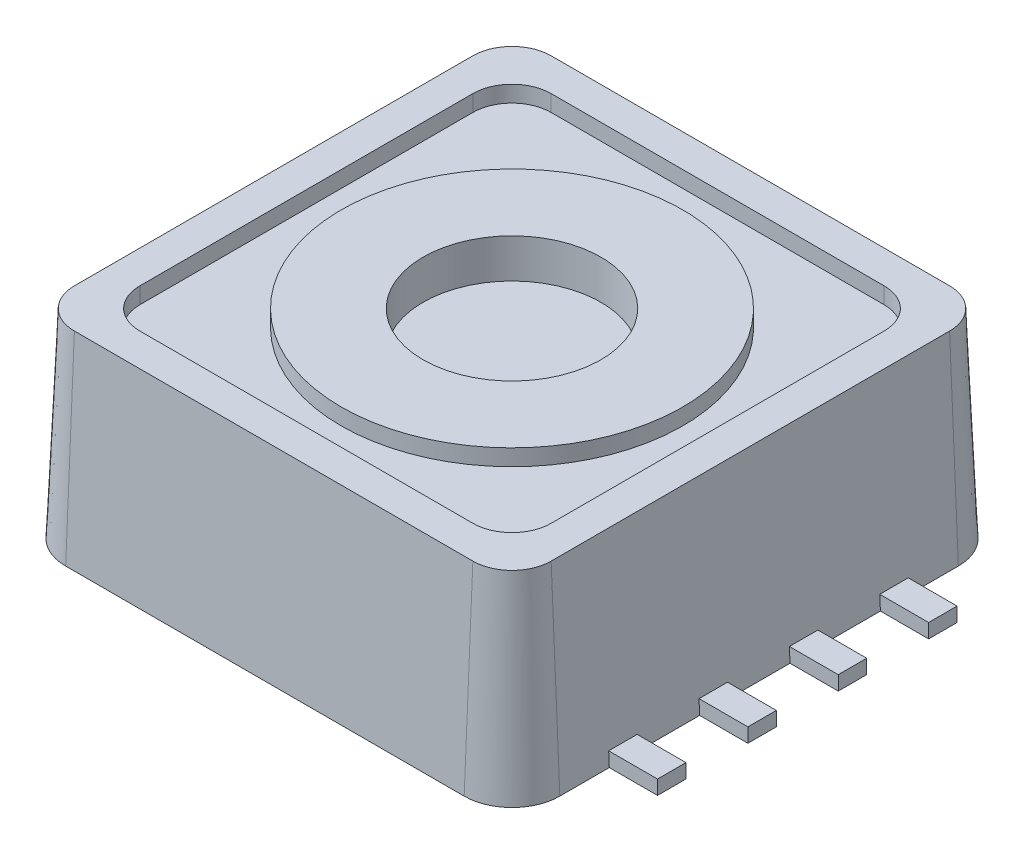
from build123d import *

# Parameters (mm, degrees)
SKETCH1_W               = 6.7
SKETCH1_H               = 6.7
BOSS_EXTRUDE1_DEPTH     = 1.4
SKETCH2_W               = 0.4
SKETCH2_H               = 0.2
BOSS_EXTRUDE2_DEPTH     = 0.8
LPATTERN1_COUNT         = 3
LPATTERN1_PITCH         = 1.27
LPATTERN1_COL_COUNT     = 2
LPATTERN1_COL_PITCH     = 1.27
MIRROR1_COPY_1_SKETCH_W = 0.4
MIRROR1_COPY_1_SKETCH_H = 0.2
MIRROR1_COPY_1_DEPTH    = 0.8
MIRROR1_COPY_2_SKETCH_W = 0.4
MIRROR1_COPY_2_SKETCH_H = 0.2
MIRROR1_COPY_2_DEPTH    = 0.8
MIRROR1_COPY_3_SKETCH_W = 0.4
MIRROR1_COPY_3_SKETCH_H = 0.2
MIRROR1_COPY_3_DEPTH    = 0.8
SKETCH3_W               = 0.8
SKETCH3_H               = 0.2
BOSS_EXTRUDE3_DEPTH     = 0.8
FILLET1_R               = 0.55
DRAFT1_ANGLE            = 2.5
SKETCH4_R               = 1.25
CUT_EXTRUDE1_DEPTH      = 0.55
SKETCH5_R               = 2.4
CUT_EXTRUDE2_DEPTH      = 0.23


with BuildPart() as part:
    # Sketch1 → Boss-Extrude1 (new, symmetric)
    with BuildSketch(Plane(origin=(0, 0, 0), x_dir=(1, 0, 0), z_dir=(0, 1, 0))):
        Rectangle(SKETCH1_W, SKETCH1_H)
    extrude(amount=BOSS_EXTRUDE1_DEPTH, both=True)

    # Sketch2 → Boss-Extrude2 (add)
    with BuildSketch(Plane(origin=(3.35, 0, 0), x_dir=(0, 0, -1), z_dir=(1, 0, 0))):
        with Locations((-0.635, -1.3)):
            Rectangle(SKETCH2_W, SKETCH2_H)
    boss_extrude2 = extrude(amount=BOSS_EXTRUDE2_DEPTH)

    # LPattern1: Boss-Extrude2 ×3
    with Locations(*[(0, 0, -i * LPATTERN1_PITCH) for i in range(1, LPATTERN1_COUNT)]):
        add(boss_extrude2)

    # LPattern1 col: Boss-Extrude2 ×2
    with Locations(*[(0, 0, i * LPATTERN1_COL_PITCH) for i in range(1, LPATTERN1_COL_COUNT)]):
        add(boss_extrude2)

    # Mirror1: Boss-Extrude2 across plane
    add(boss_extrude2.mirror(Plane(origin=(0, 0, 0), x_dir=(0, 0, 1), z_dir=(1, 0, 0))))

    # Mirror1 copy 1 sketch → Mirror1 copy 1 (add)
    with BuildSketch(Plane(origin=(-3.35, 0, -1.27), x_dir=(0, 0, -1), z_dir=(-1, 0, 0))):
        with Locations((-0.635, 1.3)):
            Rectangle(MIRROR1_COPY_1_SKETCH_W, MIRROR1_COPY_1_SKETCH_H)
    extrude(amount=MIRROR1_COPY_1_DEPTH)

    # Mirror1 copy 2 sketch → Mirror1 copy 2 (add)
    with BuildSketch(Plane(origin=(-3.35, 0, -2.54), x_dir=(0, 0, -1), z_dir=(-1, 0, 0))):
        with Locations((-0.635, 1.3)):
            Rectangle(MIRROR1_COPY_2_SKETCH_W, MIRROR1_COPY_2_SKETCH_H)
    extrude(amount=MIRROR1_COPY_2_DEPTH)

    # Mirror1 copy 3 sketch → Mirror1 copy 3 (add)
    with BuildSketch(Plane(origin=(-3.35, 0, 1.27), x_dir=(0, 0, -1), z_dir=(-1, 0, 0))):
        with Locations((-0.635, 1.3)):
            Rectangle(MIRROR1_COPY_3_SKETCH_W, MIRROR1_COPY_3_SKETCH_H)
    extrude(amount=MIRROR1_COPY_3_DEPTH)

    # Sketch3 → Boss-Extrude3 (add)
    with BuildSketch(Plane.ZY.offset(3.35)):
        with Locations((1.905, -1.3)):
            Rectangle(SKETCH3_W, SKETCH3_H)
    extrude(amount=BOSS_EXTRUDE3_DEPTH)

    # Fillet1
    fillet1_edges = [part.edges().sort_by_distance(p)[0] for p in [
        (3.35, 0, -3.35),
        (3.35, 0, 3.35),
        (-3.35, 0, 3.35),
        (-3.35, 0, -3.35),
    ]]
    fillet(fillet1_edges, radius=FILLET1_R)

    # Draft1
    draft1_faces = [part.faces().sort_by_distance(p)[0] for p in [
        (3.18890873, 0, 3.18890873),
        (3.35, 0.027083333, 0),
        (3.18890873, 0, -3.18890873),
        (-3.18890873, 0, -3.18890873),
        (-3.18890873, 0, 3.18890873),
        (0, 0, 3.35),
        (-3.35, 0.034031414, -0.009973822),
        (0, 0, -3.35),
    ]]
    draft(draft1_faces, Plane.ZX.offset(1.4), DRAFT1_ANGLE)

    # Sketch4 → Cut-Extrude1 (cut)
    with BuildSketch(Plane(origin=(0, 1.4, 0), x_dir=(1, 0, 0), z_dir=(0, 1, 0))):
        with Locations(Location((0, 0, 0), (0, 0, 270))):
            Circle(SKETCH4_R)
    extrude(amount=-CUT_EXTRUDE1_DEPTH, mode=Mode.SUBTRACT)

    # Sketch5 → Cut-Extrude2 (cut)
    with BuildSketch(Plane(origin=(0, 1.4, 0), x_dir=(1, 0, 0), z_dir=(0, 1, 0))):
        with BuildLine():
            Line((-2.34, -2.89), (2.34, -2.89))
            ThreePointArc((2.34, -2.89), (2.72890873, -2.72890873), (2.89, -2.34))
            Line((2.89, -2.34), (2.89, 2.34))
            ThreePointArc((2.89, 2.34), (2.72890873, 2.72890873), (2.34, 2.89))
            Line((2.34, 2.89), (-2.34, 2.89))
            ThreePointArc((-2.34, 2.89), (-2.72890873, 2.72890873), (-2.89, 2.34))
            Line((-2.89, 2.34), (-2.89, -2.34))
            ThreePointArc((-2.89, -2.34), (-2.72890873, -2.72890873), (-2.34, -2.89))
        make_face()
        with Locations(Location((0, 0, 0), (0, 0, 270))):
            Circle(SKETCH5_R, mode=Mode.SUBTRACT)
    extrude(amount=-CUT_EXTRUDE2_DEPTH, mode=Mode.SUBTRACT)


solid = part.part
